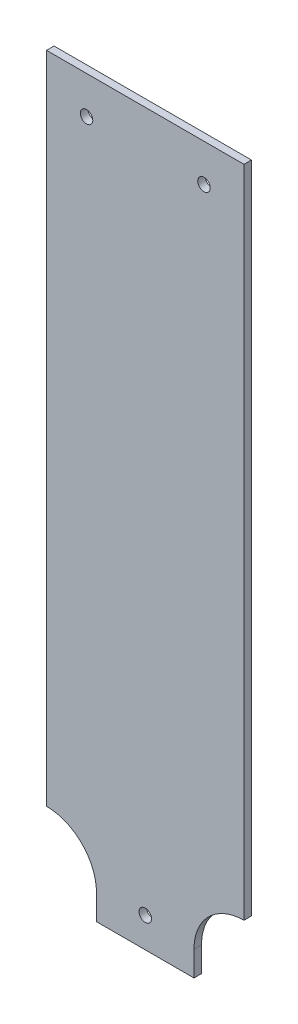
from build123d import *

# Parameters (mm, degrees)
ESQUISSE1_R      = 2.5
EXTRUSION1_DEPTH = 3


with BuildPart() as part:
    # Esquisse1 → Extrusion1 (new body)
    with BuildSketch(Plane.XY):
        with BuildLine():
            Line((39.5, 292), (-39.5, 292))
            Line((-39.5, 292), (-39.5, 30))
            ThreePointArc((-39.5, 30), (-25.357864376, 24.142135624), (-19.5, 10))
            Line((-19.5, 10), (-19.5, 0))
            Line((-19.5, 0), (19.5, 0))
            Line((19.5, 0), (19.5, 10))
            ThreePointArc((19.5, 10), (25.357864376, 24.142135624), (39.5, 30))
            Line((39.5, 30), (39.5, 292))
        make_face()
        with Locations((-23.5, 277)):
            Circle(ESQUISSE1_R, mode=Mode.SUBTRACT)
        with Locations((23.5, 277)):
            Circle(ESQUISSE1_R, mode=Mode.SUBTRACT)
        with Locations((0, 12)):
            Circle(ESQUISSE1_R, mode=Mode.SUBTRACT)
    extrude(amount=EXTRUSION1_DEPTH)


solid = part.part
